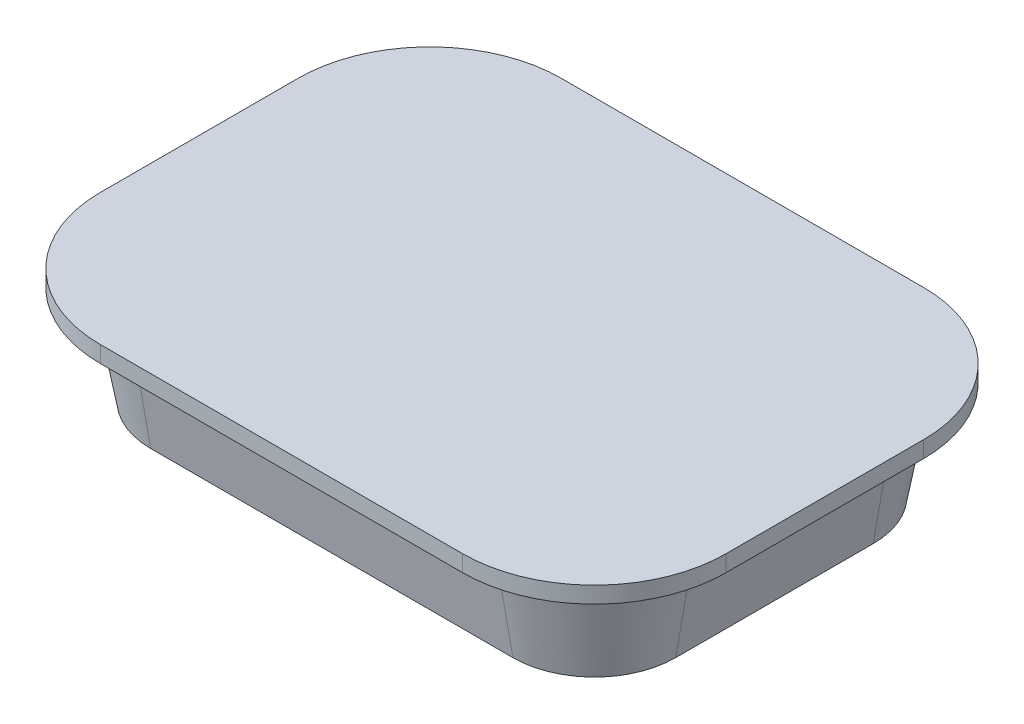
from build123d import *

# Parameters (mm, degrees)
BOSS_EXTRUDE1_DEPTH = 5
BOSS_EXTRUDE2_DEPTH = 30
BOSS_EXTRUDE2_DRAFT = -10


with BuildPart() as part:
    # Sketch1 → Boss-Extrude1 (new body)
    with BuildSketch(Plane(origin=(0, 0, 0), x_dir=(1, 0, 0), z_dir=(0, 1, 0))):
        with BuildLine():
            Line((55, 70), (-55, 70))
            ThreePointArc((-55, 70), (-83.284271247, 58.284271247), (-95, 30))
            Line((-95, 30), (-95, -30))
            ThreePointArc((-95, -30), (-83.284271247, -58.284271247), (-55, -70))
            Line((-55, -70), (55, -70))
            ThreePointArc((55, -70), (83.284271247, -58.284271247), (95, -30))
            Line((95, -30), (95, 30))
            ThreePointArc((95, 30), (83.284271247, 58.284271247), (55, 70))
        make_face()
    extrude(amount=BOSS_EXTRUDE1_DEPTH)


with BuildPart() as boss_extrude2_tool:
    # Sketch1_4 → Boss-Extrude2 (with draft: the straight prism first)
    with BuildSketch(Plane(origin=(0, 0, 0), x_dir=(1, 0, 0), z_dir=(0, 1, 0))):
        with BuildLine():
            Line((-55, -60), (55, -60))
            ThreePointArc((55, -60), (76.213203436, -51.213203436), (85, -30))
            Line((85, -30), (85, 30))
            ThreePointArc((85, 30), (76.213203436, 51.213203436), (55, 60))
            Line((55, 60), (-55, 60))
            ThreePointArc((-55, 60), (-76.213203436, 51.213203436), (-85, 30))
            Line((-85, 30), (-85, -30))
            ThreePointArc((-85, -30), (-76.213203436, -51.213203436), (-55, -60))
        make_face()
    extrude(amount=-BOSS_EXTRUDE2_DEPTH)
    # Boss-Extrude2: the draft: its side faces are tilted about the plane it starts from
    boss_extrude2_sides = [boss_extrude2_tool.faces().sort_by_distance(p)[0] for p in [
        (0, -15, 60),
        (76.213203436, -15, 51.213203436),
        (85, -15, 0),
        (76.213203436, -15, -51.213203436),
        (0, -15, -60),
        (-76.213203436, -15, -51.213203436),
        (-85, -15, 0),
        (-76.213203436, -15, 51.213203436),
    ]]
    draft(boss_extrude2_sides, Plane(origin=(0, 0, 0), x_dir=(1, 0, 0), z_dir=(0, 1, 0)), BOSS_EXTRUDE2_DRAFT)


with BuildPart() as part_1:
    add(part.part)

    # Boss-Extrude2: add boss_extrude2_tool
    add(boss_extrude2_tool.part)


solid = part_1.part
